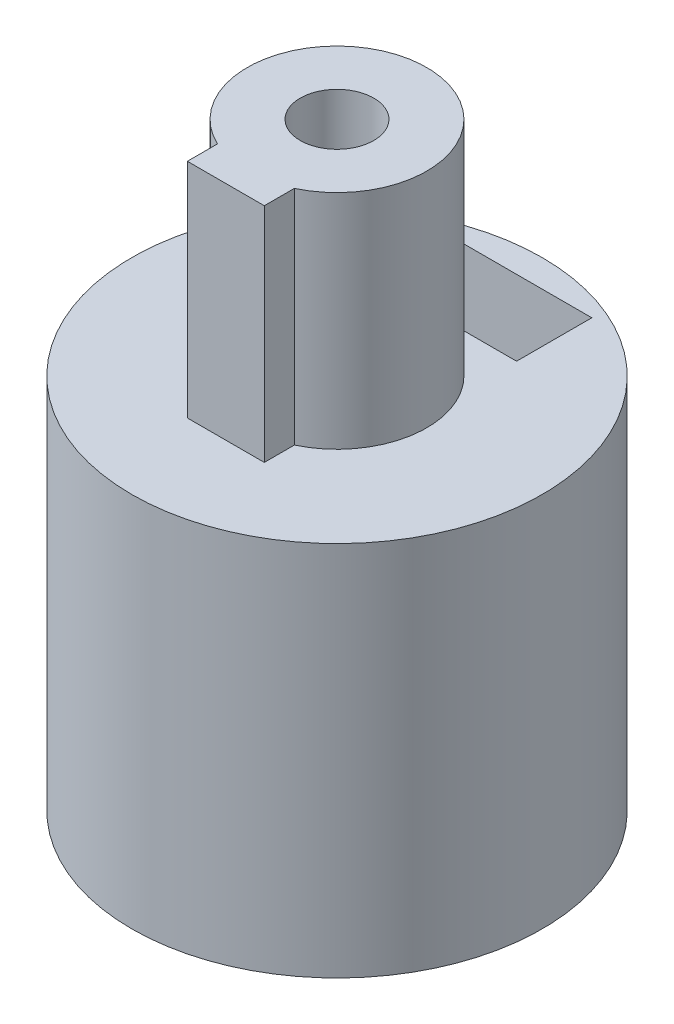
from build123d import *

# Parameters (mm, degrees)
SKETCH1_R           = 6
BOSS_EXTRUDE1_DEPTH = 10
SKETCH2_R           = 1.025
CUT_EXTRUDE1_DEPTH  = 7
SKETCH4_R           = 2.275
CUT_EXTRUDE4_DEPTH  = 11.0000001
SKETCH5_W           = 0.95
SKETCH5_H           = 7.069146706
BOSS_EXTRUDE2_DEPTH = 1.2
SKETCH7_R           = 6
BOSS_EXTRUDE3_DEPTH = 1
SKETCH8_R           = 2.625
SKETCH8_W           = 2.25
SKETCH8_H           = 1.25
BOSS_EXTRUDE4_DEPTH = 6.5
SKETCH9_R           = 1.075
CUT_EXTRUDE5_DEPTH  = 6
CUT_EXTRUDE2_START  = -3
CUT_EXTRUDE2_DEPTH  = 2.2


with BuildPart() as part:
    # Sketch1 → Boss-Extrude1 (new body)
    with BuildSketch(Plane(origin=(0, 0, 0), x_dir=(1, 0, 0), z_dir=(0, 1, 0))):
        Circle(SKETCH1_R)
    extrude(amount=BOSS_EXTRUDE1_DEPTH)

    # Sketch2 → Cut-Extrude1 (cut, through all)
    with BuildSketch(Plane.XY):
        with Locations((0, 7)):
            Circle(SKETCH2_R)
    extrude(amount=-CUT_EXTRUDE1_DEPTH, mode=Mode.SUBTRACT)

    # Sketch4 → Cut-Extrude4 (cut, through all)
    with BuildSketch(Plane(origin=(0, 0, 0), x_dir=(1, 0, 0), z_dir=(0, 1, 0))):
        Circle(SKETCH4_R)
    extrude(amount=CUT_EXTRUDE4_DEPTH, mode=Mode.SUBTRACT)

    # Sketch5 → Boss-Extrude2 (add)
    with BuildSketch(Plane(origin=(0, 10, 0), x_dir=(1, 0, 0), z_dir=(0, 1, 0))):
        Rectangle(SKETCH5_W, SKETCH5_H)
    extrude(amount=-BOSS_EXTRUDE2_DEPTH)

    # Sketch7 → Boss-Extrude3 (add)
    with BuildSketch(Plane(origin=(0, 10, 0), x_dir=(1, 0, 0), z_dir=(0, 1, 0))):
        Circle(SKETCH7_R)
    extrude(amount=BOSS_EXTRUDE3_DEPTH)

    # Sketch8 → Boss-Extrude4 (add)
    with BuildSketch(Plane(origin=(0, 11, 0), x_dir=(1, 0, 0), z_dir=(0, 1, 0))):
        Circle(SKETCH8_R)
        with Locations((0, -2.625)):
            Rectangle(SKETCH8_W, SKETCH8_H)
    extrude(amount=BOSS_EXTRUDE4_DEPTH)

    # Sketch9 → Cut-Extrude5 (cut)
    with BuildSketch(Plane(origin=(0, 17.5, 0), x_dir=(1, 0, 0), z_dir=(0, 1, 0))):
        Circle(SKETCH9_R)
    extrude(amount=-CUT_EXTRUDE5_DEPTH, mode=Mode.SUBTRACT)

    # Sketch3 → Cut-Extrude2 (cut)
    with BuildSketch(Plane.XY.offset(CUT_EXTRUDE2_START)):
        Polygon((0, 4.401923789), (2.25, 5.700961894), (2.25, 8.299038106), (2.25, 11.472802467), (-2.25, 11.472802467), (-2.25, 8.299038106), (-2.25, 5.700961894), align=None)
    extrude(amount=-CUT_EXTRUDE2_DEPTH, mode=Mode.SUBTRACT)


solid = part.part
